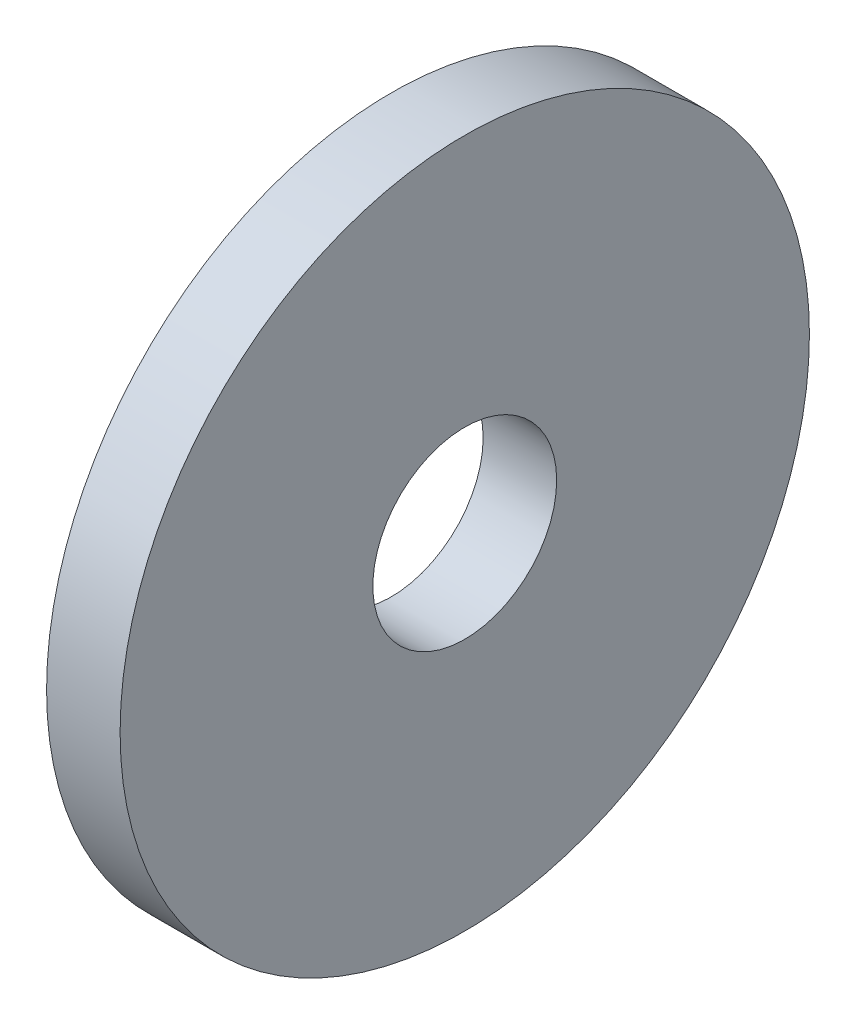
from build123d import *

# Parameters (mm, degrees)
SKETCH1_R           = 37.5
BOSS_EXTRUDE1_DEPTH = 8
SKETCH2_R           = 10
CUT_EXTRUDE1_DEPTH  = 9


with BuildPart() as part:
    # Sketch1 → Boss-Extrude1 (new body)
    with BuildSketch(Plane(origin=(0, 0, 0), x_dir=(0, 0, -1), z_dir=(1, 0, 0))):
        Circle(SKETCH1_R)
    extrude(amount=BOSS_EXTRUDE1_DEPTH)

    # Sketch2 → Cut-Extrude1 (cut, through all)
    with BuildSketch(Plane(origin=(8, 0, 0), x_dir=(0, 0, -1), z_dir=(1, 0, 0))):
        Circle(SKETCH2_R)
    extrude(amount=-CUT_EXTRUDE1_DEPTH, mode=Mode.SUBTRACT)


solid = part.part
